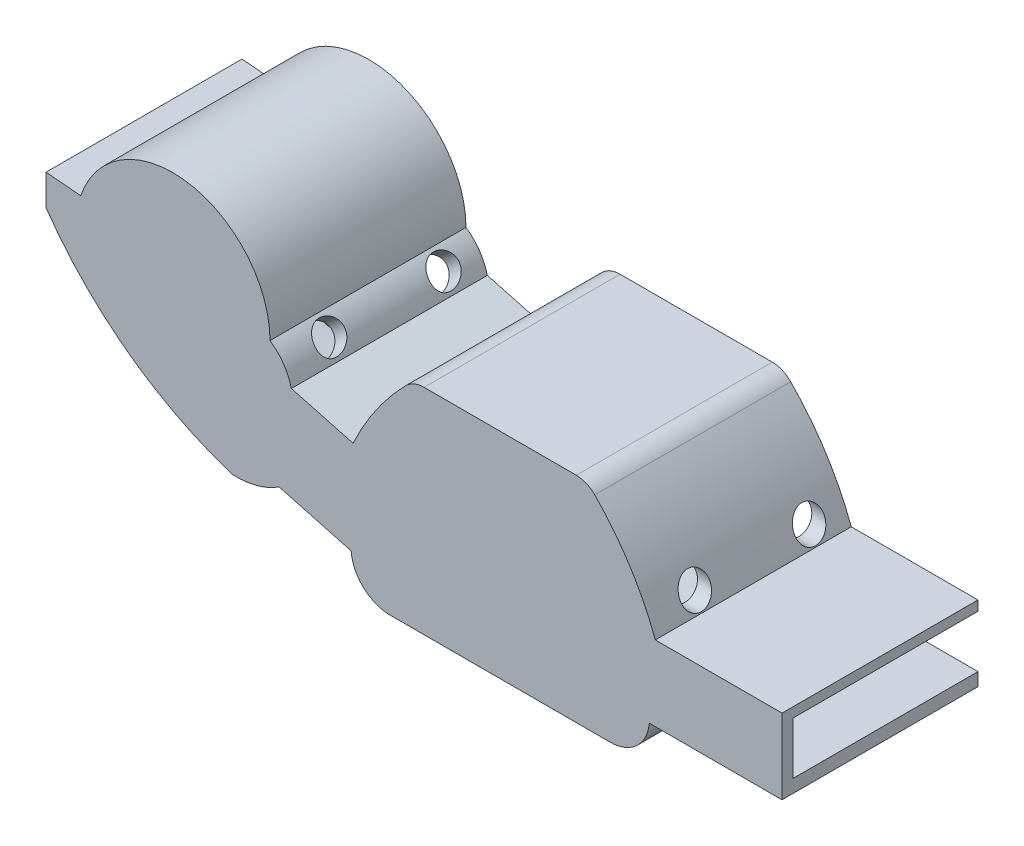
from build123d import *

# Parameters (mm, degrees)
WALLS_DEPTH                    = 16
BASE_DEPTH                     = 1
CUT_EXTRUDE2_REACH             = 91.482
CUT_EXTRUDE2_START             = 25
SKETCH14_R                     = 1.4
CUT_EXTRUDE3_REACH             = 60.126
SKETCH15_R                     = 1.4
CUT_EXTRUDE4_REACH             = 27.942
SKETCH16_R                     = 1.4
CUT_EXTRUDE4_DIRECTION_2_REACH = 44.073
CUT_EXTRUDE6_DEPTH             = 1
CUT_EXTRUDE7_START             = 1
SKETCH20_W                     = 0.5
SKETCH20_H                     = 5.968950485
CUT_EXTRUDE7_DEPTH             = 13
CUT_EXTRUDE8_START             = -1
SKETCH21_W                     = 1.2
SKETCH21_H                     = 4.8
CUT_EXTRUDE8_DEPTH             = 17
BOSS_EXTRUDE7_DEPTH            = 1


with BuildPart() as part:
    # Sketch1 → Walls (new body)
    with BuildSketch(Plane.XY):
        with BuildLine():
            Line((-2.714226626, -4.104973799), (9.481662569, -4.104973799))
            Line((9.481662569, -4.104973799), (9.481662569, 2.795026201))
            Line((9.481662569, 2.795026201), (-2.157765014, 2.795026201))
            ThreePointArc((-2.157765014, 2.795026201), (-4.475421171, 7.467506564), (-7.720187416, 11.551021571))
            ThreePointArc((-7.720187416, 11.551021571), (-8.494484922, 12.081481284), (-9.414311331, 12.268145448))
            Line((-9.414311331, 12.268145448), (-23.396800773, 12.268145448))
            ThreePointArc((-23.396800773, 12.268145448), (-24.316627182, 12.081481284), (-25.090924688, 11.551021571))
            ThreePointArc((-25.090924688, 11.551021571), (-27.807855973, 8.264014675), (-29.920645216, 4.559658921))
            Line((-29.920645216, 4.559658921), (-35.58589456, 6.080016678))
            ThreePointArc((-35.58589456, 6.080016678), (-36.30623543, 7.677493642), (-37.54731346, 8.914647207))
            ThreePointArc((-37.54731346, 8.914647207), (-45.043473284, 17.696136771), (-54.937924272, 11.745774536))
            Line((-54.937924272, 11.745774536), (-58.126384329, 12.017293347))
            Line((-58.126384329, 12.017293347), (-58.126384329, 9.185725557))
            ThreePointArc((-58.126384329, 9.185725557), (-50.607055304, 1.462964307), (-41.021791027, -3.466950402))
            ThreePointArc((-41.021791027, -3.466950402), (-38.77519769, -3.231928947), (-36.710658995, -2.315361062))
            Line((-36.710658995, -2.315361062), (-34.413426971, -2.931858998))
            Line((-34.413426971, -2.931858998), (-30.102483127, -4.088767815))
            ThreePointArc((-30.102483127, -4.088767815), (-28.95951903, -6.454996499), (-26.512978021, -7.414080542))
            Line((-26.512978021, -7.414080542), (-6.302454756, -7.414080542))
            ThreePointArc((-6.302454756, -7.414080542), (-3.861882663, -6.460513587), (-2.714226626, -4.104973799))
        make_face()
        with BuildLine():
            Line((-11.180694354, 10.652027), (-11.480694354, 9.152027))
            Line((-11.480694354, 9.152027), (-11.780694354, 10.652027))
            Line((-11.780694354, 10.652027), (-12.480694354, 10.652027))
            Line((-12.480694354, 10.652027), (-12.780694354, 9.152027))
            Line((-12.780694354, 9.152027), (-13.080694354, 10.652027))
            Line((-13.080694354, 10.652027), (-13.754684343, 10.652027))
            Line((-13.754684343, 10.652027), (-14.054684343, 9.152027))
            Line((-14.054684343, 9.152027), (-14.354684343, 10.652027))
            Line((-14.354684343, 10.652027), (-15.054684343, 10.652027))
            Line((-15.054684343, 10.652027), (-15.354684343, 9.152027))
            Line((-15.354684343, 9.152027), (-15.654684343, 10.652027))
            Line((-15.654684343, 10.652027), (-16.354684343, 10.652027))
            Line((-16.354684343, 10.652027), (-16.654684343, 9.152027))
            Line((-16.654684343, 9.152027), (-16.954684343, 10.652027))
            Line((-16.954684343, 10.652027), (-17.654684343, 10.652027))
            Line((-17.654684343, 10.652027), (-17.954684343, 9.152027))
            Line((-17.954684343, 9.152027), (-18.254684343, 10.652027))
            Line((-18.254684343, 10.652027), (-18.954684343, 10.652027))
            Line((-18.954684343, 10.652027), (-19.254684343, 9.152027))
            Line((-19.254684343, 9.152027), (-19.554684343, 10.652027))
            Line((-19.554684343, 10.652027), (-20.254684343, 10.652027))
            Line((-20.254684343, 10.652027), (-20.554684343, 9.152027))
            Line((-20.554684343, 9.152027), (-20.854684343, 10.652027))
            Line((-20.854684343, 10.652027), (-21.554684343, 10.652027))
            Line((-21.554684343, 10.652027), (-21.854684343, 9.152027))
            Line((-21.854684343, 9.152027), (-22.154684343, 10.652027))
            Line((-22.154684343, 10.652027), (-22.854684343, 10.652027))
            Line((-22.854684343, 10.652027), (-23.154684343, 9.152027))
            Line((-23.154684343, 9.152027), (-23.457941673, 10.657707986))
            ThreePointArc((-23.457941673, 10.657707986), (-24.295920105, 10.483827589), (-24.983754411, 9.974586769))
            ThreePointArc((-24.983754411, 9.974586769), (-25.343038743, 9.372290059), (-25.468103034, 8.682213628))
            ThreePointArc((-25.468103034, 8.682213628), (-27.891258334, 6.284887251), (-29.092774814, 3.095026201))
            Line((-29.092774814, 3.095026201), (-36.819376584, 5.168579936))
            ThreePointArc((-36.819376584, 5.168579936), (-37.372292188, 6.785798937), (-38.544266032, 8.029820749))
            ThreePointArc((-38.544266032, 8.029820749), (-38.683065987, 9.884394902), (-39.244266032, 11.657461517))
            Line((-39.244266032, 11.657461517), (-39.544266032, 9.657461517))
            Line((-39.544266032, 9.657461517), (-39.844266032, 12.754923747))
            ThreePointArc((-39.844266032, 12.754923747), (-40.177694618, 13.227773766), (-40.544266032, 13.675420011))
            Line((-40.544266032, 13.675420011), (-40.844266032, 12.475420011))
            Line((-40.844266032, 12.475420011), (-41.144266032, 14.287455982))
            ThreePointArc((-41.144266032, 14.287455982), (-41.486206213, 14.583667887), (-41.844266032, 14.860177824))
            Line((-41.844266032, 14.860177824), (-42.144266032, 13.760177824))
            Line((-42.144266032, 13.760177824), (-42.444266032, 15.2573102))
            ThreePointArc((-42.444266032, 15.2573102), (-42.789650362, 15.452886191), (-43.144266032, 15.631178172))
            Line((-43.144266032, 15.631178172), (-43.444266032, 14.631178172))
            Line((-43.444266032, 14.631178172), (-43.744266032, 15.885310402))
            ThreePointArc((-43.744266032, 15.885310402), (-44.091660411, 16.007109254), (-44.444266032, 16.112878297))
            Line((-44.444266032, 16.112878297), (-44.744266032, 15.062878297))
            Line((-44.744266032, 15.062878297), (-45.044266032, 16.253487135))
            ThreePointArc((-45.044266032, 16.253487135), (-45.393118463, 16.313314876), (-45.744266032, 16.357730656))
            Line((-45.744266032, 16.357730656), (-46.044266032, 15.257730656))
            Line((-46.044266032, 15.257730656), (-46.344266032, 16.397629841))
            ThreePointArc((-46.344266032, 16.397629841), (-46.695004455, 16.400148657), (-47.045518973, 16.387367493))
            Line((-47.045518973, 16.387367493), (-47.345518973, 15.196758655))
            Line((-47.345518973, 15.196758655), (-47.645518973, 16.329737175))
            ThreePointArc((-47.645518973, 16.329737175), (-47.995798063, 16.27489653), (-48.343318782, 16.204666282))
            Line((-48.343318782, 16.204666282), (-48.643318782, 14.947553607))
            Line((-48.643318782, 14.947553607), (-48.943318782, 16.045004147))
            ThreePointArc((-48.943318782, 16.045004147), (-49.295962777, 15.927429638), (-49.642795213, 15.793680569))
            Line((-49.642795213, 15.793680569), (-49.942795213, 14.493680569))
            Line((-49.942795213, 14.493680569), (-50.242795213, 15.516848429))
            ThreePointArc((-50.242795213, 15.516848429), (-50.596924915, 15.324091577), (-50.940945863, 15.113823565))
            Line((-50.940945863, 15.113823565), (-51.240945863, 13.613823565))
            Line((-51.240945863, 13.613823565), (-51.540945863, 14.685890874))
            ThreePointArc((-51.540945863, 14.685890874), (-51.900746334, 14.386191477), (-52.242488541, 14.066053427))
            Line((-52.242488541, 14.066053427), (-52.542488541, 12.166053427))
            Line((-52.542488541, 12.166053427), (-52.842488541, 13.399785487))
            ThreePointArc((-52.842488541, 13.399785487), (-53.946059214, 11.577074768), (-54.532074338, 9.528482844))
            ThreePointArc((-54.532074338, 9.528482844), (-54.938887237, 9.362114059), (-55.341456987, 9.185725557))
            Line((-55.341456987, 9.185725557), (-56.999219422, 10.304574836))
            Line((-56.999219422, 10.304574836), (-57.384896759, 10.745232528))
            Line((-57.384896759, 10.745232528), (-57.384896759, 10.009091265))
            Line((-57.384896759, 10.009091265), (-54.087398152, 6.065354763))
            ThreePointArc((-54.087398152, 6.065354763), (-48.380823268, 0.937091135), (-41.463701487, -2.382172492))
            ThreePointArc((-41.463701487, -2.382172492), (-39.411904378, -2.199815414), (-37.961376996, -0.737250614))
            Line((-37.961376996, -0.737250614), (-29.111357457, -3.112290976))
            ThreePointArc((-29.111357457, -3.112290976), (-28.254867391, -5.315073251), (-26.069092729, -6.214080542))
            Line((-26.069092729, -6.214080542), (-6.746340048, -6.214080542))
            ThreePointArc((-6.746340048, -6.214080542), (-4.489094638, -5.239633694), (-3.718337431, -2.904973799))
            Line((-3.718337431, -2.904973799), (8.281662569, -2.904973799))
            Line((8.281662569, -2.904973799), (8.281662569, 1.895026201))
            Line((8.281662569, 1.895026201), (-3.634781843, 1.895026201))
            ThreePointArc((-3.634781843, 1.895026201), (-4.611558125, 5.76795929), (-7.34300907, 8.682213628))
            ThreePointArc((-7.34300907, 8.682213628), (-8.12308073, 9.896738229), (-9.353170431, 10.652027))
            Line((-9.353170431, 10.652027), (-9.906704364, 10.652027))
            Line((-9.906704364, 10.652027), (-10.206704364, 9.152027))
            Line((-10.206704364, 9.152027), (-10.506704364, 10.652027))
            Line((-10.506704364, 10.652027), (-11.180694354, 10.652027))
        make_face(mode=Mode.SUBTRACT)
    extrude(amount=WALLS_DEPTH)

    # Sketch2 → Base (add)
    with BuildSketch(Plane(origin=(0, 0, 0), x_dir=(-1, 0, 0), z_dir=(0, 0, -1))):
        with BuildLine():
            Line((35.58589456, 6.080016678), (29.920645216, 4.559658921))
            ThreePointArc((29.920645216, 4.559658921), (27.807855973, 8.264014675), (25.090924688, 11.551021571))
            ThreePointArc((25.090924688, 11.551021571), (24.316627182, 12.081481284), (23.396800773, 12.268145448))
            Line((23.396800773, 12.268145448), (9.414311331, 12.268145448))
            ThreePointArc((9.414311331, 12.268145448), (8.494484922, 12.081481284), (7.720187416, 11.551021571))
            ThreePointArc((7.720187416, 11.551021571), (4.475421171, 7.467506564), (2.157765014, 2.795026201))
            Line((2.157765014, 2.795026201), (-9.481662569, 2.795026201))
            Line((-9.481662569, 2.795026201), (-9.481662569, -4.104973799))
            Line((-9.481662569, -4.104973799), (2.714226626, -4.104973799))
            ThreePointArc((2.714226626, -4.104973799), (3.861882663, -6.460513587), (6.302454756, -7.414080542))
            Line((6.302454756, -7.414080542), (26.512978021, -7.414080542))
            ThreePointArc((26.512978021, -7.414080542), (28.95951903, -6.454996499), (30.102483127, -4.088767815))
            Line((30.102483127, -4.088767815), (36.710658995, -2.315361062))
            ThreePointArc((36.710658995, -2.315361062), (38.77519769, -3.231928947), (41.021791027, -3.466950402))
            ThreePointArc((41.021791027, -3.466950402), (50.607055304, 1.462964307), (58.126384329, 9.185725557))
            Line((58.126384329, 9.185725557), (58.126384329, 12.017293347))
            Line((58.126384329, 12.017293347), (54.937924272, 11.745774536))
            ThreePointArc((54.937924272, 11.745774536), (45.043473284, 17.696136771), (37.54731346, 8.914647207))
            ThreePointArc((37.54731346, 8.914647207), (36.30623543, 7.677493642), (35.58589456, 6.080016678))
        make_face()
    extrude(amount=BASE_DEPTH)

    # Sketch14 → Cut-Extrude2 (cut, up to next)
    with BuildSketch(Plane(origin=(-55, 0, 0), x_dir=(0, 0, -1), z_dir=(1, 0, 0)).offset(CUT_EXTRUDE2_START), mode=Mode.PRIVATE) as cut_extrude2_sk1:
        with Locations((-12.75, 6.610008351)):
            Circle(SKETCH14_R)
    cut_extrude2_tool1 = extrude(cut_extrude2_sk1.sketch, amount=CUT_EXTRUDE2_REACH, mode=Mode.PRIVATE) & part.part
    add(cut_extrude2_tool1.solids().sort_by_distance((-30, 6.610008, 12.75))[0], mode=Mode.SUBTRACT)
    # Sketch14 → Cut-Extrude2 (cut, up to next)
    with BuildSketch(Plane(origin=(-55, 0, 0), x_dir=(0, 0, -1), z_dir=(1, 0, 0)).offset(CUT_EXTRUDE2_START), mode=Mode.PRIVATE) as cut_extrude2_sk2:
        with Locations((-2.25, 6.610008351)):
            Circle(SKETCH14_R)
    cut_extrude2_tool2 = extrude(cut_extrude2_sk2.sketch, amount=CUT_EXTRUDE2_REACH, mode=Mode.PRIVATE) & part.part
    add(cut_extrude2_tool2.solids().sort_by_distance((-30, 6.610008, 2.25))[0], mode=Mode.SUBTRACT)

    # Sketch15 → Cut-Extrude3 (cut, up to next)
    with BuildSketch(Plane(origin=(0, 0, 0), x_dir=(0, 0, -1), z_dir=(1, 0, 0)), mode=Mode.PRIVATE) as cut_extrude3_sk1:
        with Locations((-12.75, 4.295026201)):
            Circle(SKETCH15_R)
    cut_extrude3_tool1 = extrude(cut_extrude3_sk1.sketch, amount=-CUT_EXTRUDE3_REACH, mode=Mode.PRIVATE) & part.part
    add(cut_extrude3_tool1.solids().sort_by_distance((0, 4.295026, 12.75))[0], mode=Mode.SUBTRACT)
    # Sketch15 → Cut-Extrude3 (cut, up to next)
    with BuildSketch(Plane(origin=(0, 0, 0), x_dir=(0, 0, -1), z_dir=(1, 0, 0)), mode=Mode.PRIVATE) as cut_extrude3_sk2:
        with Locations((-2.25, 4.295026201)):
            Circle(SKETCH15_R)
    cut_extrude3_tool2 = extrude(cut_extrude3_sk2.sketch, amount=-CUT_EXTRUDE3_REACH, mode=Mode.PRIVATE) & part.part
    add(cut_extrude3_tool2.solids().sort_by_distance((0, 4.295026, 2.25))[0], mode=Mode.SUBTRACT)

    # Sketch16 → Cut-Extrude4 (cut, up to next)
    with BuildSketch(Plane(origin=(-17.902858946, -15.010436061, 0), x_dir=(0, 0, -1), z_dir=(0.766294061, 0.642490009, 0)), mode=Mode.PRIVATE) as cut_extrude4_sk1:
        with Locations((-12.75, 29.238838688)):
            Circle(SKETCH16_R)
    cut_extrude4_tool1 = extrude(cut_extrude4_sk1.sketch, amount=-CUT_EXTRUDE4_REACH, mode=Mode.PRIVATE) & part.part
    add(cut_extrude4_tool1.solids().sort_by_distance((-36.688521, 7.395112, 12.75))[0], mode=Mode.SUBTRACT)
    add(cut_extrude4_tool1.solids().sort_by_distance((-36.688521, 7.395112, 12.75))[1], mode=Mode.SUBTRACT)
    # Sketch16 → Cut-Extrude4 (cut, up to next)
    with BuildSketch(Plane(origin=(-17.902858946, -15.010436061, 0), x_dir=(0, 0, -1), z_dir=(0.766294061, 0.642490009, 0)), mode=Mode.PRIVATE) as cut_extrude4_sk2:
        with Locations((-2.25, 29.238838688)):
            Circle(SKETCH16_R)
    cut_extrude4_tool2 = extrude(cut_extrude4_sk2.sketch, amount=-CUT_EXTRUDE4_REACH, mode=Mode.PRIVATE) & part.part
    add(cut_extrude4_tool2.solids().sort_by_distance((-36.688521, 7.395112, 2.25))[0], mode=Mode.SUBTRACT)
    add(cut_extrude4_tool2.solids().sort_by_distance((-36.688521, 7.395112, 2.25))[1], mode=Mode.SUBTRACT)

    # Sketch16 → Cut-Extrude4 direction 2 (cut, up to next)
    with BuildSketch(Plane(origin=(-17.902858946, -15.010436061, 0), x_dir=(0, 0, -1), z_dir=(0.766294061, 0.642490009, 0)), mode=Mode.PRIVATE) as cut_extrude4_direction_2_sk1:
        with Locations((-12.75, 29.238838688)):
            Circle(SKETCH16_R)
    cut_extrude4_direction_2_tool1 = extrude(cut_extrude4_direction_2_sk1.sketch, amount=CUT_EXTRUDE4_DIRECTION_2_REACH, mode=Mode.PRIVATE) & part.part
    add(cut_extrude4_direction_2_tool1.solids().sort_by_distance((-36.688521, 7.395112, 12.75))[0], mode=Mode.SUBTRACT)
    # Sketch16 → Cut-Extrude4 direction 2 (cut, up to next)
    with BuildSketch(Plane(origin=(-17.902858946, -15.010436061, 0), x_dir=(0, 0, -1), z_dir=(0.766294061, 0.642490009, 0)), mode=Mode.PRIVATE) as cut_extrude4_direction_2_sk2:
        with Locations((-2.25, 29.238838688)):
            Circle(SKETCH16_R)
    cut_extrude4_direction_2_tool2 = extrude(cut_extrude4_direction_2_sk2.sketch, amount=CUT_EXTRUDE4_DIRECTION_2_REACH, mode=Mode.PRIVATE) & part.part
    add(cut_extrude4_direction_2_tool2.solids().sort_by_distance((-36.688521, 7.395112, 2.25))[0], mode=Mode.SUBTRACT)

    # Sketch19 → Cut-Extrude6 (cut)
    with BuildSketch(Plane.XY):
        with BuildLine():
            Line((-11.180694354, 10.652027), (-11.480694354, 9.152027))
            Line((-11.480694354, 9.152027), (-11.780694354, 10.652027))
            Line((-11.780694354, 10.652027), (-12.480694354, 10.652027))
            Line((-12.480694354, 10.652027), (-12.780694354, 9.152027))
            Line((-12.780694354, 9.152027), (-13.080694354, 10.652027))
            Line((-13.080694354, 10.652027), (-13.754684343, 10.652027))
            Line((-13.754684343, 10.652027), (-14.054684343, 9.152027))
            Line((-14.054684343, 9.152027), (-14.354684343, 10.652027))
            Line((-14.354684343, 10.652027), (-15.054684343, 10.652027))
            Line((-15.054684343, 10.652027), (-15.354684343, 9.152027))
            Line((-15.354684343, 9.152027), (-15.654684343, 10.652027))
            Line((-15.654684343, 10.652027), (-16.354684343, 10.652027))
            Line((-16.354684343, 10.652027), (-16.654684343, 9.152027))
            Line((-16.654684343, 9.152027), (-16.954684343, 10.652027))
            Line((-16.954684343, 10.652027), (-17.654684343, 10.652027))
            Line((-17.654684343, 10.652027), (-17.954684343, 9.152027))
            Line((-17.954684343, 9.152027), (-18.254684343, 10.652027))
            Line((-18.254684343, 10.652027), (-18.954684343, 10.652027))
            Line((-18.954684343, 10.652027), (-19.254684343, 9.152027))
            Line((-19.254684343, 9.152027), (-19.554684343, 10.652027))
            Line((-19.554684343, 10.652027), (-20.254684343, 10.652027))
            Line((-20.254684343, 10.652027), (-20.554684343, 9.152027))
            Line((-20.554684343, 9.152027), (-20.854684343, 10.652027))
            Line((-20.854684343, 10.652027), (-21.554684343, 10.652027))
            Line((-21.554684343, 10.652027), (-21.854684343, 9.152027))
            Line((-21.854684343, 9.152027), (-22.154684343, 10.652027))
            Line((-22.154684343, 10.652027), (-22.854684343, 10.652027))
            Line((-22.854684343, 10.652027), (-23.154684343, 9.152027))
            Line((-23.154684343, 9.152027), (-23.457941673, 10.657707986))
            ThreePointArc((-23.457941673, 10.657707986), (-24.295920105, 10.483827589), (-24.983754411, 9.974586769))
            ThreePointArc((-24.983754411, 9.974586769), (-25.343038743, 9.372290059), (-25.468103034, 8.682213628))
            ThreePointArc((-25.468103034, 8.682213628), (-27.891258334, 6.284887251), (-29.092774814, 3.095026201))
            Line((-29.092774814, 3.095026201), (-36.819376584, 5.168579936))
            ThreePointArc((-36.819376584, 5.168579936), (-37.372292188, 6.785798937), (-38.544266032, 8.029820749))
            ThreePointArc((-38.544266032, 8.029820749), (-38.683065987, 9.884394902), (-39.244266032, 11.657461517))
            Line((-39.244266032, 11.657461517), (-39.544266032, 9.657461517))
            Line((-39.544266032, 9.657461517), (-39.844266032, 12.754923747))
            ThreePointArc((-39.844266032, 12.754923747), (-40.177694618, 13.227773766), (-40.544266032, 13.675420011))
            Line((-40.544266032, 13.675420011), (-40.844266032, 12.475420011))
            Line((-40.844266032, 12.475420011), (-41.144266032, 14.287455982))
            ThreePointArc((-41.144266032, 14.287455982), (-41.486206213, 14.583667887), (-41.844266032, 14.860177824))
            Line((-41.844266032, 14.860177824), (-42.144266032, 13.760177824))
            Line((-42.144266032, 13.760177824), (-42.444266032, 15.2573102))
            ThreePointArc((-42.444266032, 15.2573102), (-42.789650362, 15.452886191), (-43.144266032, 15.631178172))
            Line((-43.144266032, 15.631178172), (-43.444266032, 14.631178172))
            Line((-43.444266032, 14.631178172), (-43.744266032, 15.885310402))
            ThreePointArc((-43.744266032, 15.885310402), (-44.091660411, 16.007109254), (-44.444266032, 16.112878297))
            Line((-44.444266032, 16.112878297), (-44.744266032, 15.062878297))
            Line((-44.744266032, 15.062878297), (-45.044266032, 16.253487135))
            ThreePointArc((-45.044266032, 16.253487135), (-45.393118463, 16.313314876), (-45.744266032, 16.357730656))
            Line((-45.744266032, 16.357730656), (-46.044266032, 15.257730656))
            Line((-46.044266032, 15.257730656), (-46.344266032, 16.397629841))
            ThreePointArc((-46.344266032, 16.397629841), (-46.695004455, 16.400148657), (-47.045518973, 16.387367493))
            Line((-47.045518973, 16.387367493), (-47.345518973, 15.196758655))
            Line((-47.345518973, 15.196758655), (-47.645518973, 16.329737175))
            ThreePointArc((-47.645518973, 16.329737175), (-47.995798063, 16.27489653), (-48.343318782, 16.204666282))
            Line((-48.343318782, 16.204666282), (-48.643318782, 14.947553607))
            Line((-48.643318782, 14.947553607), (-48.943318782, 16.045004147))
            ThreePointArc((-48.943318782, 16.045004147), (-49.295962777, 15.927429638), (-49.642795213, 15.793680569))
            Line((-49.642795213, 15.793680569), (-49.942795213, 14.493680569))
            Line((-49.942795213, 14.493680569), (-50.242795213, 15.516848429))
            ThreePointArc((-50.242795213, 15.516848429), (-50.596924915, 15.324091577), (-50.940945863, 15.113823565))
            Line((-50.940945863, 15.113823565), (-51.240945863, 13.613823565))
            Line((-51.240945863, 13.613823565), (-51.540945863, 14.685890874))
            ThreePointArc((-51.540945863, 14.685890874), (-51.900746334, 14.386191477), (-52.242488541, 14.066053427))
            Line((-52.242488541, 14.066053427), (-52.542488541, 12.166053427))
            Line((-52.542488541, 12.166053427), (-52.842488541, 13.399785487))
            ThreePointArc((-52.842488541, 13.399785487), (-53.946059214, 11.577074768), (-54.532074338, 9.528482844))
            ThreePointArc((-54.532074338, 9.528482844), (-54.938887237, 9.362114059), (-55.341456987, 9.185725557))
            Line((-55.341456987, 9.185725557), (-56.999219422, 10.304574836))
            Line((-56.999219422, 10.304574836), (-57.384896759, 10.745232528))
            Line((-57.384896759, 10.745232528), (-57.384896759, 10.009091265))
            Line((-57.384896759, 10.009091265), (-54.087398152, 6.065354763))
            ThreePointArc((-54.087398152, 6.065354763), (-48.380823268, 0.937091135), (-41.463701487, -2.382172492))
            ThreePointArc((-41.463701487, -2.382172492), (-39.411904378, -2.199815414), (-37.961376996, -0.737250614))
            Line((-37.961376996, -0.737250614), (-29.111357457, -3.112290976))
            ThreePointArc((-29.111357457, -3.112290976), (-28.254867391, -5.315073251), (-26.069092729, -6.214080542))
            Line((-26.069092729, -6.214080542), (-6.746340048, -6.214080542))
            ThreePointArc((-6.746340048, -6.214080542), (-4.489094638, -5.239633694), (-3.718337431, -2.904973799))
            Line((-3.718337431, -2.904973799), (8.281662569, -2.904973799))
            Line((8.281662569, -2.904973799), (8.281662569, 1.895026201))
            Line((8.281662569, 1.895026201), (-3.634781843, 1.895026201))
            ThreePointArc((-3.634781843, 1.895026201), (-4.611558125, 5.76795929), (-7.34300907, 8.682213628))
            ThreePointArc((-7.34300907, 8.682213628), (-8.12308073, 9.896738229), (-9.353170431, 10.652027))
            Line((-9.353170431, 10.652027), (-9.906704364, 10.652027))
            Line((-9.906704364, 10.652027), (-10.206704364, 9.152027))
            Line((-10.206704364, 9.152027), (-10.506704364, 10.652027))
            Line((-10.506704364, 10.652027), (-11.180694354, 10.652027))
        make_face()
    extrude(amount=-CUT_EXTRUDE6_DEPTH, mode=Mode.SUBTRACT)

    # Sketch20 → Cut-Extrude7 (cut)
    with BuildSketch(Plane.XY.offset(CUT_EXTRUDE7_START)):
        Polygon((-54.403521594, 2.709264477), (-51.924554873, 5.126381587), (-51.590284725, 4.753970352), (-54.054462304, 2.351273398), align=None)
        Polygon((-42.683035997, -1.118777258), (-43.714617636, -3.854201703), (-43.246779839, -4.030632415), (-42.2151982, -1.295207969), align=None)
        with Locations((-16.417467247, -6.356352563)):
            Rectangle(SKETCH20_W, SKETCH20_H)
    extrude(amount=CUT_EXTRUDE7_DEPTH, mode=Mode.SUBTRACT)

    # Sketch21 → Cut-Extrude8 (cut)
    with BuildSketch(Plane.XY.offset(CUT_EXTRUDE8_START)):
        with Locations((8.881662569, -0.504973799)):
            Rectangle(SKETCH21_W, SKETCH21_H)
    extrude(amount=CUT_EXTRUDE8_DEPTH, mode=Mode.SUBTRACT)

    # Sketch22 → Boss-Extrude7 (add)
    with BuildSketch(Plane.XY.offset(16)):
        with BuildLine():
            Line((-2.714226626, -4.104973799), (9.481662569, -4.104973799))
            Line((9.481662569, -4.104973799), (9.481662569, 2.795026201))
            Line((9.481662569, 2.795026201), (-2.157765014, 2.795026201))
            ThreePointArc((-2.157765014, 2.795026201), (-4.475421171, 7.467506564), (-7.720187416, 11.551021571))
            ThreePointArc((-7.720187416, 11.551021571), (-8.494484922, 12.081481284), (-9.414311331, 12.268145448))
            Line((-9.414311331, 12.268145448), (-23.396800773, 12.268145448))
            ThreePointArc((-23.396800773, 12.268145448), (-24.316627182, 12.081481284), (-25.090924688, 11.551021571))
            ThreePointArc((-25.090924688, 11.551021571), (-27.807855973, 8.264014675), (-29.920645216, 4.559658921))
            Line((-29.920645216, 4.559658921), (-35.58589456, 6.080016678))
            ThreePointArc((-35.58589456, 6.080016678), (-36.30623543, 7.677493642), (-37.54731346, 8.914647207))
            ThreePointArc((-37.54731346, 8.914647207), (-45.043473284, 17.696136771), (-54.937924272, 11.745774536))
            Line((-54.937924272, 11.745774536), (-58.126384329, 12.017293347))
            Line((-58.126384329, 12.017293347), (-58.126384329, 9.185725557))
            ThreePointArc((-58.126384329, 9.185725557), (-50.607055304, 1.462964307), (-41.021791027, -3.466950402))
            ThreePointArc((-41.021791027, -3.466950402), (-38.77519769, -3.231928947), (-36.710658995, -2.315361062))
            Line((-36.710658995, -2.315361062), (-34.413426971, -2.931858998))
            Line((-34.413426971, -2.931858998), (-30.102483127, -4.088767815))
            ThreePointArc((-30.102483127, -4.088767815), (-28.95951903, -6.454996499), (-26.512978021, -7.414080542))
            Line((-26.512978021, -7.414080542), (-6.302454756, -7.414080542))
            ThreePointArc((-6.302454756, -7.414080542), (-3.861882663, -6.460513587), (-2.714226626, -4.104973799))
        make_face()
    extrude(amount=BOSS_EXTRUDE7_DEPTH)


solid = part.part
